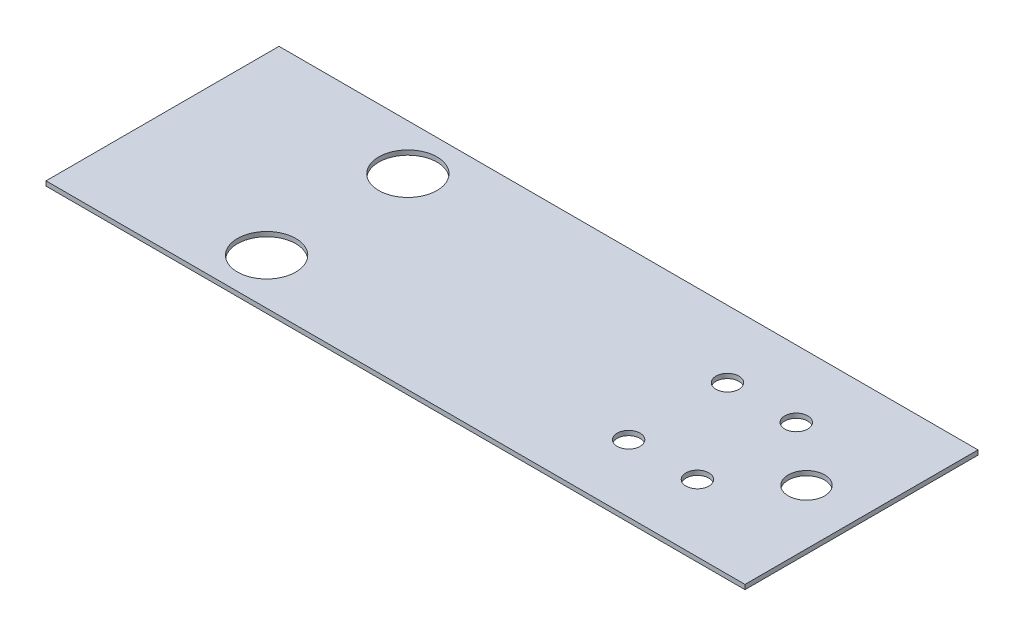
from build123d import *

# Parameters (mm, degrees)
ESQUISSE1_W             = 152.4
ESQUISSE1_H             = 50.8
BOSS_EXTRU_1_DEPTH      = 1
ESQUISSE2_R             = 6.35
ENL_V_MAT_EXTRU_1_DEPTH = 1
ESQUISSE3_R             = 2.5
ENL_V_MAT_EXTRU_2_DEPTH = 1
ESQUISSE4_R             = 3.96875
ENL_V_MAT_EXTRU_3_DEPTH = 1


with BuildPart() as part:
    # Esquisse1 → Boss.-Extru.1 (new body)
    with BuildSketch(Plane(origin=(0, 0, 0), x_dir=(1, 0, 0), z_dir=(0, 1, 0))):
        Rectangle(ESQUISSE1_W, ESQUISSE1_H)
    extrude(amount=BOSS_EXTRU_1_DEPTH)

    # Esquisse2 → Enlèv. mat.-Extru.1 (cut)
    with BuildSketch(Plane(origin=(0, 1, 0), x_dir=(1, 0, 0), z_dir=(0, 1, 0))):
        with Locations((-38.1, 15.4)):
            Circle(ESQUISSE2_R)
        with Locations((-38.1, -15.4)):
            Circle(ESQUISSE2_R)
    extrude(amount=-ENL_V_MAT_EXTRU_1_DEPTH, mode=Mode.SUBTRACT)

    # Esquisse3 → Enlèv. mat.-Extru.2 (cut)
    with BuildSketch(Plane(origin=(0, 1, 0), x_dir=(1, 0, 0), z_dir=(0, 1, 0))):
        with Locations((51.2, 10.775)):
            Circle(ESQUISSE3_R)
        with Locations((36.2, 10.775)):
            Circle(ESQUISSE3_R)
        with Locations((36.2, -10.775)):
            Circle(ESQUISSE3_R)
        with Locations((51.2, -10.775)):
            Circle(ESQUISSE3_R)
    extrude(amount=-ENL_V_MAT_EXTRU_2_DEPTH, mode=Mode.SUBTRACT)

    # Esquisse4 → Enlèv. mat.-Extru.3 (cut)
    with BuildSketch(Plane(origin=(0, 1, 0), x_dir=(1, 0, 0), z_dir=(0, 1, 0))):
        with Locations((64.2, 0)):
            Circle(ESQUISSE4_R)
    extrude(amount=-ENL_V_MAT_EXTRU_3_DEPTH, mode=Mode.SUBTRACT)


solid = part.part
